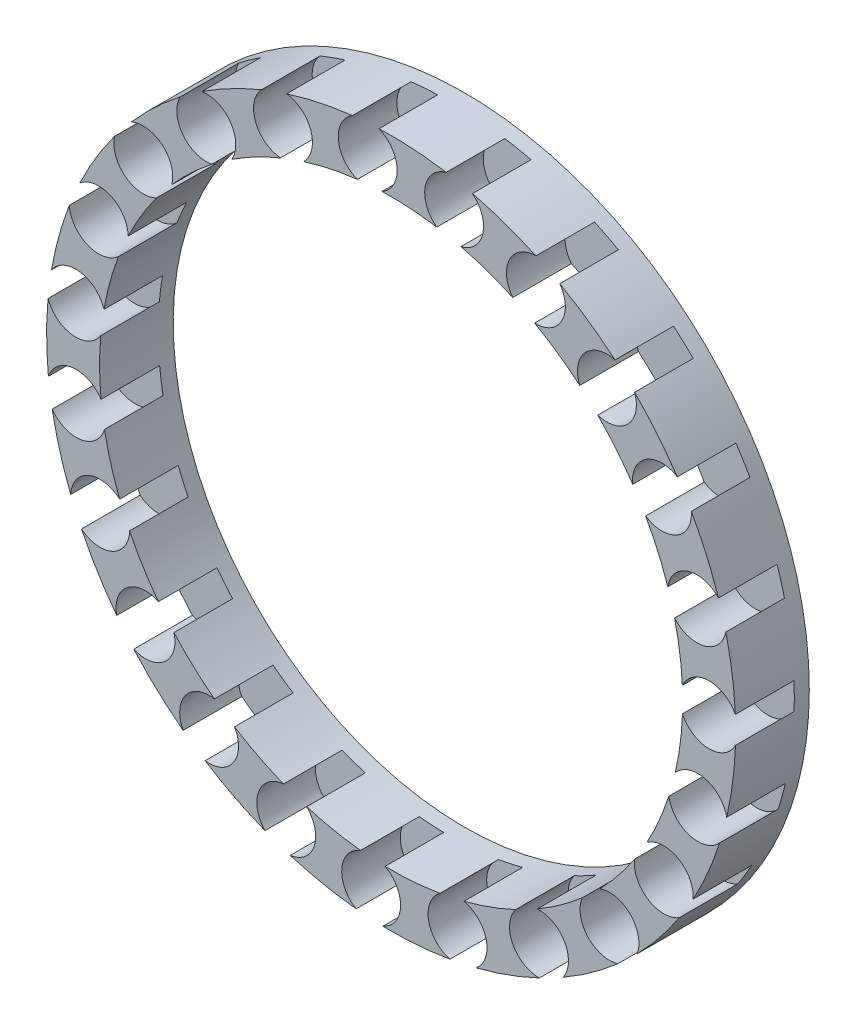
from build123d import *

# Parameters (mm, degrees)
SKETCH_1_R               = 23.4
SKETCH_1_R_2             = 19.8
EXTRUDE_1_DEPTH          = 5
SKETCH_2_W               = 4
SKETCH_2_H               = 2
PATTERN_CIRCULAR_1_COUNT = 23


with BuildPart() as part:
    # 草图1 → 凸台-拉伸1 (new body)
    with BuildSketch(Plane.XY):
        Circle(SKETCH_1_R)
        Circle(SKETCH_1_R_2, mode=Mode.SUBTRACT)
    extrude(amount=EXTRUDE_1_DEPTH)

    # 草图2 → 切除-旋转1 (revolve, cut)
    with BuildSketch(Plane(origin=(21.6, 0, 0), x_dir=(0, 0, -1), z_dir=(1, 0, 0))):
        with Locations((-3.020321316, 1.11760291)):
            Rectangle(SKETCH_2_W, SKETCH_2_H)
    cut_revolve_1 = revolve(axis=Axis((21.6, 0.11760291, 5.020321316), (0, 0, -1)), mode=Mode.SUBTRACT)

    # 阵列(圆周)1: 切除-旋转1 ×23 about axis
    pattern_circular_1_axis = Axis((0, 0, 0), (0, 0, 1))
    for i in range(1, PATTERN_CIRCULAR_1_COUNT):
        add(cut_revolve_1.rotate(pattern_circular_1_axis, i * 360 / PATTERN_CIRCULAR_1_COUNT), mode=Mode.SUBTRACT)


solid = part.part
